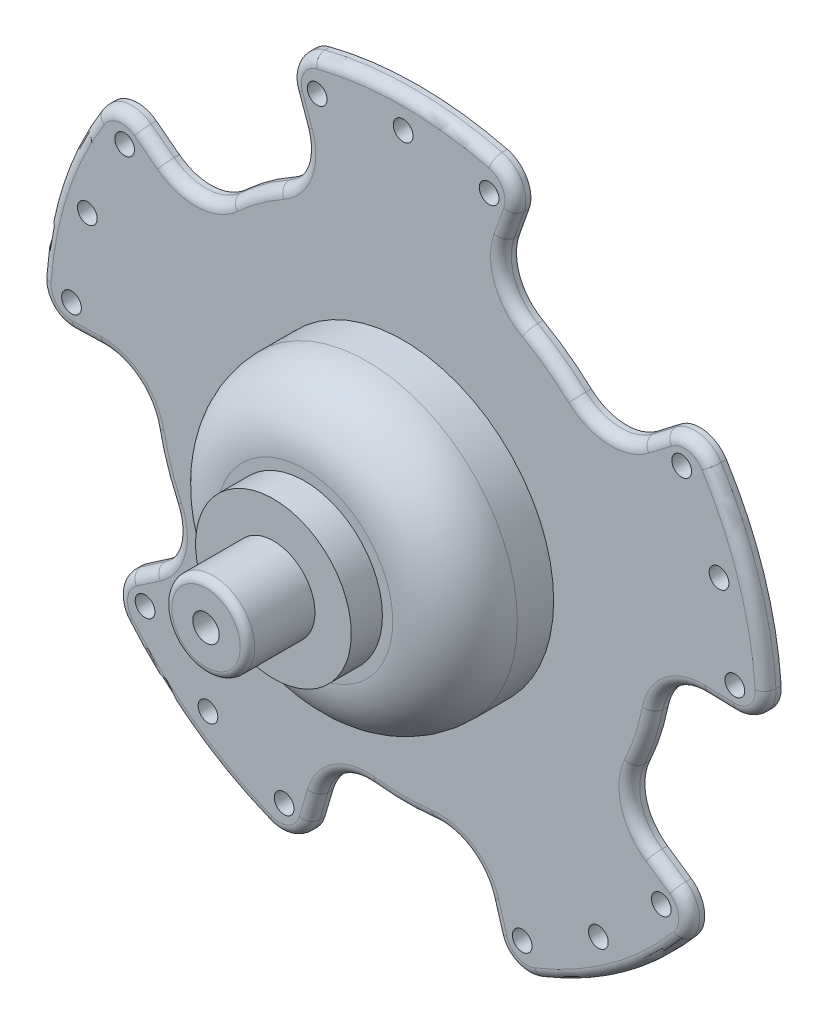
from build123d import *
from build123d.topology import SkipClean

# Parameters (mm, degrees)
SKETCH1_R                   = 35
SKETCH1_R_2                 = 12.5
BOSS_EXTRUDE1_DEPTH         = 1.5
SKETCH5_R                   = 0.95
CUT_EXTRUDE1_DEPTH          = 50.520197899
CIRPATTERN4_COUNT           = 2
CIRPATTERN4_ANGLE           = 15
CIRPATTERN3_COUNT           = 2
CIRPATTERN3_ANGLE           = 15
SKETCH2_R                   = 14.5
SKETCH2_R_2                 = 12.5
EXTRUDE_THIN1_DEPTH         = 9.5
CIRPATTERN1_COUNT           = 5
CIRPATTERN1_COPY_1_SKETCH_R = 0.95
CIRPATTERN1_COPY_1_DEPTH    = 50.520197899
CIRPATTERN1_COPY_2_SKETCH_R = 0.95
CIRPATTERN1_COPY_2_DEPTH    = 50.520197899
CIRPATTERN1_COPY_3_SKETCH_R = 0.95
CIRPATTERN1_COPY_3_DEPTH    = 50.520197899
CIRPATTERN1_COPY_4_SKETCH_R = 0.95
CIRPATTERN1_COPY_4_DEPTH    = 50.520197899
CIRPATTERN1_COPY_5_SKETCH_R = 0.95
CIRPATTERN1_COPY_5_DEPTH    = 50.520197899
CIRPATTERN1_COPY_6_SKETCH_R = 0.95
CIRPATTERN1_COPY_6_DEPTH    = 50.520197899
CIRPATTERN1_COPY_7_SKETCH_R = 0.95
CIRPATTERN1_COPY_7_DEPTH    = 50.520197899
CIRPATTERN1_COPY_8_SKETCH_R = 0.95
CIRPATTERN1_COPY_8_DEPTH    = 50.520197899
BOSS_EXTRUDE2_START         = -8
SKETCH3_R                   = 12.5
SKETCH3_R_2                 = 1.275
BOSS_EXTRUDE2_DEPTH         = 3
FILLET1_R                   = 3
FILLET2_R                   = 6
SKETCH6_R                   = 4
SKETCH6_R_2                 = 1.275
BOSS_EXTRUDE3_DEPTH         = 9.5
SKETCH7_R                   = 7.5
SKETCH7_R_2                 = 4
BOSS_EXTRUDE4_DEPTH         = 3
CUT_EXTRUDE2_DEPTH          = 54.018864567
FILLET3_R                   = 3
FILLET4_R                   = 5
CIRPATTERN2_COUNT           = 5
FILLET3_OF_CIRPATTERN2_R    = 3
FILLET4_OF_CIRPATTERN2_R    = 5
FILLET5_R                   = 1
FILLET6_R                   = 0.7


with BuildPart() as part:
    # Sketch1 → Boss-Extrude1 (new body)
    with BuildSketch(Plane.XY):
        Circle(SKETCH1_R)
        Circle(SKETCH1_R_2, mode=Mode.SUBTRACT)
    extrude(amount=BOSS_EXTRUDE1_DEPTH)

    # Sketch5 → Cut-Extrude1 (cut, through all)
    with BuildSketch(Plane.XY.offset(1.5)):
        with Locations((0, 32)):
            Circle(SKETCH5_R)
    cut_extrude1 = extrude(amount=-CUT_EXTRUDE1_DEPTH, mode=Mode.SUBTRACT)

    # CirPattern4: Cut-Extrude1 ×2 about axis
    cirpattern4_axis = Axis((0, 0, -88.99), (0, 0, -1))
    for i in range(1, CIRPATTERN4_COUNT):
        add(cut_extrude1.rotate(cirpattern4_axis, i * CIRPATTERN4_ANGLE / (CIRPATTERN4_COUNT - 1)), mode=Mode.SUBTRACT)

    # CirPattern3: Cut-Extrude1 ×2 about axis
    cirpattern3_axis = Axis((0, 0, -88.99), (0, 0, 1))
    for i in range(1, CIRPATTERN3_COUNT):
        add(cut_extrude1.rotate(cirpattern3_axis, i * CIRPATTERN3_ANGLE / (CIRPATTERN3_COUNT - 1)), mode=Mode.SUBTRACT)

    # Sketch2 → Extrude-Thin1 (add)
    with BuildSketch(Plane.XY.offset(1.5)):
        Circle(SKETCH2_R)
        Circle(SKETCH2_R_2, mode=Mode.SUBTRACT)
    extrude(amount=EXTRUDE_THIN1_DEPTH)

    # CirPattern1: Cut-Extrude1 ×5 about axis
    cirpattern1_axis = Axis((0, 0, -88.99), (0, 0, 1))
    for i in range(1, CIRPATTERN1_COUNT):
        add(cut_extrude1.rotate(cirpattern1_axis, i * 360 / CIRPATTERN1_COUNT), mode=Mode.SUBTRACT)

    # CirPattern1 copy 1 sketch → CirPattern1 copy 1 (cut, through all)
    with BuildSketch(Plane(origin=(0, 0, 1.5), x_dir=(0.5446390350150276, 0.8386705679454236, 0), z_dir=(0, 0, 1))):
        with Locations((0, 32)):
            Circle(CIRPATTERN1_COPY_1_SKETCH_R)
    extrude(amount=-CIRPATTERN1_COPY_1_DEPTH, mode=Mode.SUBTRACT)

    # CirPattern1 copy 2 sketch → CirPattern1 copy 2 (cut, through all)
    with BuildSketch(Plane(origin=(0, 0, 1.5), x_dir=(-0.6293203910498368, 0.7771459614569713, 0), z_dir=(0, 0, 1))):
        with Locations((0, 32)):
            Circle(CIRPATTERN1_COPY_2_SKETCH_R)
    extrude(amount=-CIRPATTERN1_COPY_2_DEPTH, mode=Mode.SUBTRACT)

    # CirPattern1 copy 3 sketch → CirPattern1 copy 3 (cut, through all)
    with BuildSketch(Plane(origin=(0, 0, 1.5), x_dir=(-0.9335804264972021, -0.3583679495452995, 0), z_dir=(0, 0, 1))):
        with Locations((0, 32)):
            Circle(CIRPATTERN1_COPY_3_SKETCH_R)
    extrude(amount=-CIRPATTERN1_COPY_3_DEPTH, mode=Mode.SUBTRACT)

    # CirPattern1 copy 4 sketch → CirPattern1 copy 4 (cut, through all)
    with BuildSketch(Plane(origin=(0, 0, 1.5), x_dir=(0.05233595624294293, -0.9986295347545739, 0), z_dir=(0, 0, 1))):
        with Locations((0, 32)):
            Circle(CIRPATTERN1_COPY_4_SKETCH_R)
    extrude(amount=-CIRPATTERN1_COPY_4_DEPTH, mode=Mode.SUBTRACT)

    # CirPattern1 copy 5 sketch → CirPattern1 copy 5 (cut, through all)
    with BuildSketch(Plane(origin=(0, 0, 1.5), x_dir=(0.05233595624294324, 0.9986295347545739, 0), z_dir=(0, 0, 1))):
        with Locations((0, 32)):
            Circle(CIRPATTERN1_COPY_5_SKETCH_R)
    extrude(amount=-CIRPATTERN1_COPY_5_DEPTH, mode=Mode.SUBTRACT)

    # CirPattern1 copy 6 sketch → CirPattern1 copy 6 (cut, through all)
    with BuildSketch(Plane(origin=(0, 0, 1.5), x_dir=(-0.9335804264972019, 0.3583679495452998, 0), z_dir=(0, 0, 1))):
        with Locations((0, 32)):
            Circle(CIRPATTERN1_COPY_6_SKETCH_R)
    extrude(amount=-CIRPATTERN1_COPY_6_DEPTH, mode=Mode.SUBTRACT)

    # CirPattern1 copy 7 sketch → CirPattern1 copy 7 (cut, through all)
    with BuildSketch(Plane(origin=(0, 0, 1.5), x_dir=(-0.6293203910498371, -0.7771459614569711, 0), z_dir=(0, 0, 1))):
        with Locations((0, 32)):
            Circle(CIRPATTERN1_COPY_7_SKETCH_R)
    extrude(amount=-CIRPATTERN1_COPY_7_DEPTH, mode=Mode.SUBTRACT)

    # CirPattern1 copy 8 sketch → CirPattern1 copy 8 (cut, through all)
    with BuildSketch(Plane(origin=(0, 0, 1.5), x_dir=(0.5446390350150274, -0.8386705679454238, 0), z_dir=(0, 0, 1))):
        with Locations((0, 32)):
            Circle(CIRPATTERN1_COPY_8_SKETCH_R)
    extrude(amount=-CIRPATTERN1_COPY_8_DEPTH, mode=Mode.SUBTRACT)

    # Sketch3 → Boss-Extrude2 (add)
    with BuildSketch(Plane(origin=(0, 0, 0), x_dir=(-1, 0, 0), z_dir=(0, 0, -1)).offset(BOSS_EXTRUDE2_START)):
        Circle(SKETCH3_R)
        Circle(SKETCH3_R_2, mode=Mode.SUBTRACT)
    extrude(amount=-BOSS_EXTRUDE2_DEPTH)

    # Fillet1
    fillet1_edges = [part.edges().sort_by_distance(p)[0] for p in [
        (-12.5, 0, 8),
    ]]
    fillet(fillet1_edges, radius=FILLET1_R)

    # Fillet2
    fillet2_edges = [part.edges().sort_by_distance(p)[0] for p in [
        (-14.5, 0, 11),
    ]]
    fillet(fillet2_edges, radius=FILLET2_R)

    # Sketch6 → Boss-Extrude3 (add)
    with SkipClean():  # the faces are left unmerged after this step: merging them gives an invalid solid
        with BuildSketch(Plane.XY.offset(11)):
            Circle(SKETCH6_R)
            Circle(SKETCH6_R_2, mode=Mode.SUBTRACT)
        extrude(amount=BOSS_EXTRUDE3_DEPTH)

    # Sketch7 → Boss-Extrude4 (add)
    with SkipClean():  # the faces are left unmerged after this step: merging them gives an invalid solid
        with BuildSketch(Plane.XY.offset(11)):
            Circle(SKETCH7_R)
            Circle(SKETCH7_R_2, mode=Mode.SUBTRACT)
        extrude(amount=BOSS_EXTRUDE4_DEPTH)

    # Sketch8 → Cut-Extrude2 (cut, through all)
    with SkipClean():  # the faces are left unmerged after this step: merging them gives an invalid solid
        with BuildSketch(Plane.XY.offset(1.5)):
            with BuildLine():
                Line((11.683240073, 32.992452188), (8.178268051, 23.094716532))
                ThreePointArc((8.178268051, 23.094716532), (14.400738681, 19.820916362), (19.437156837, 14.914655011))
                Line((19.437156837, 14.914655011), (27.76736691, 21.306650015))
                ThreePointArc((27.76736691, 21.306650015), (20.57248383, 28.315594803), (11.683240073, 32.992452188))
            make_face()
        cut_extrude2 = extrude(amount=-CUT_EXTRUDE2_DEPTH, mode=Mode.SUBTRACT)

    # Fillet3
    fillet3_edges = [part.edges().sort_by_distance(p)[0] for p in [
        (27.76736691, 21.306650015, 0.75),
        (11.683240073, 32.992452188, 0.75),
    ]]
    fillet(fillet3_edges, radius=FILLET3_R)

    # Fillet4
    fillet4_edges = [part.edges().sort_by_distance(p)[0] for p in [
        (19.437156837, 14.914655011, 0.75),
        (8.178268051, 23.094716532, 0.75),
    ]]
    fillet(fillet4_edges, radius=FILLET4_R)

    # CirPattern2: Cut-Extrude2 ×5 about axis
    cirpattern2_axis = Axis((0, 0, -88.99), (0, 0, 1))
    for i in range(1, CIRPATTERN2_COUNT):
        add(cut_extrude2.rotate(cirpattern2_axis, i * 360 / CIRPATTERN2_COUNT), mode=Mode.SUBTRACT)

    # Fillet3 of CirPattern2
    fillet3_of_cirpattern2_edges = [part.edges().sort_by_distance(p)[0] for p in [
        (-11.683240073, 32.992452188, 0.75),
        (-27.76736691, 21.306650015, 0.75),
        (-34.988006374, -0.916193191, 0.75),
        (-28.844416602, -19.824218292, 0.75),
        (-9.940537065, -33.55869072, 0.75),
        (9.940537065, -33.55869072, 0.75),
        (28.844416602, -19.824218292, 0.75),
        (34.988006374, -0.916193191, 0.75),
    ]]
    fillet(fillet3_of_cirpattern2_edges, radius=FILLET3_OF_CIRPATTERN2_R)

    # Fillet4 of CirPattern2
    fillet4_of_cirpattern2_edges = [part.edges().sort_by_distance(p)[0] for p in [
        (-8.178268051, 23.094716532, 0.75),
        (-19.437156837, 14.914655011, 0.75),
        (-24.491604462, -0.641335234, 0.75),
        (-20.191091621, -13.876952805, 0.75),
        (-6.958375945, -23.491083504, 0.75),
        (6.958375945, -23.491083504, 0.75),
        (20.191091621, -13.876952805, 0.75),
        (24.491604462, -0.641335234, 0.75),
    ]]
    fillet(fillet4_of_cirpattern2_edges, radius=FILLET4_OF_CIRPATTERN2_R)

    # Fillet5
    fillet5_edges = [part.edges().sort_by_distance(p)[0] for p in [
        (-27.632502529, 19.967192075, 1.5),
        (-24.170401306, 18.546601233, 1.5),
        (-19.792865663, 16.670629554, 1.5),
        (-14.400738681, 19.820916362, 1.5),
        (-9.73837901, 23.975641704, 1.5),
        (-10.169801193, 28.718632633, 1.5),
        (-10.451015257, 32.450273273, 1.5),
        (0, 35, 1.5),
        (10.451015257, 32.450273273, 1.5),
        (10.169801193, 28.718632633, 1.5),
        (9.73837901, 23.975641704, 1.5),
        (14.400738681, 19.820916362, 1.5),
        (19.792865663, 16.670629554, 1.5),
        (24.170401306, 18.546601233, 1.5),
        (27.632502529, 19.967192075, 1.5),
        (33.28697807, 10.815594803, 1.5),
        (34.091585174, 0.088179751, 1.5),
        (30.455684102, -0.797510155, 1.5),
        (25.811514887, -1.852868078, 1.5),
        (23.300884649, -7.570916362, 1.5),
        (21.971042725, -13.672626026, 1.5),
        (25.107930722, -17.256202695, 1.5),
        (27.528841014, -20.10986991, 1.5),
        (20.57248383, -28.315594803, 1.5),
        (10.618743111, -32.395775189, 1.5),
        (8.652846733, -29.211521015, 1.5),
        (6.214014491, -25.120777153, 1.5),
        (0, -24.5, 1.5),
        (-6.214014491, -25.120777153, 1.5),
        (-8.652846733, -29.211521015, 1.5),
        (-10.618743111, -32.395775189, 1.5),
        (-20.57248383, -28.315594803, 1.5),
        (-27.528841014, -20.10986991, 1.5),
        (-25.107930722, -17.256202695, 1.5),
        (-21.971042725, -13.672626026, 1.5),
        (-23.300884649, -7.570916362, 1.5),
        (-25.811514887, -1.852868078, 1.5),
        (-30.455684102, -0.797510155, 1.5),
        (-34.091585174, 0.088179751, 1.5),
        (-33.28697807, 10.815594803, 1.5),
    ]]
    fillet(fillet5_edges, radius=FILLET5_R)

    # Fillet6
    fillet6_edges = [part.edges().sort_by_distance(p)[0] for p in [
        (-4, 0, 20.5),
    ]]
    fillet(fillet6_edges, radius=FILLET6_R)


solid = part.part
